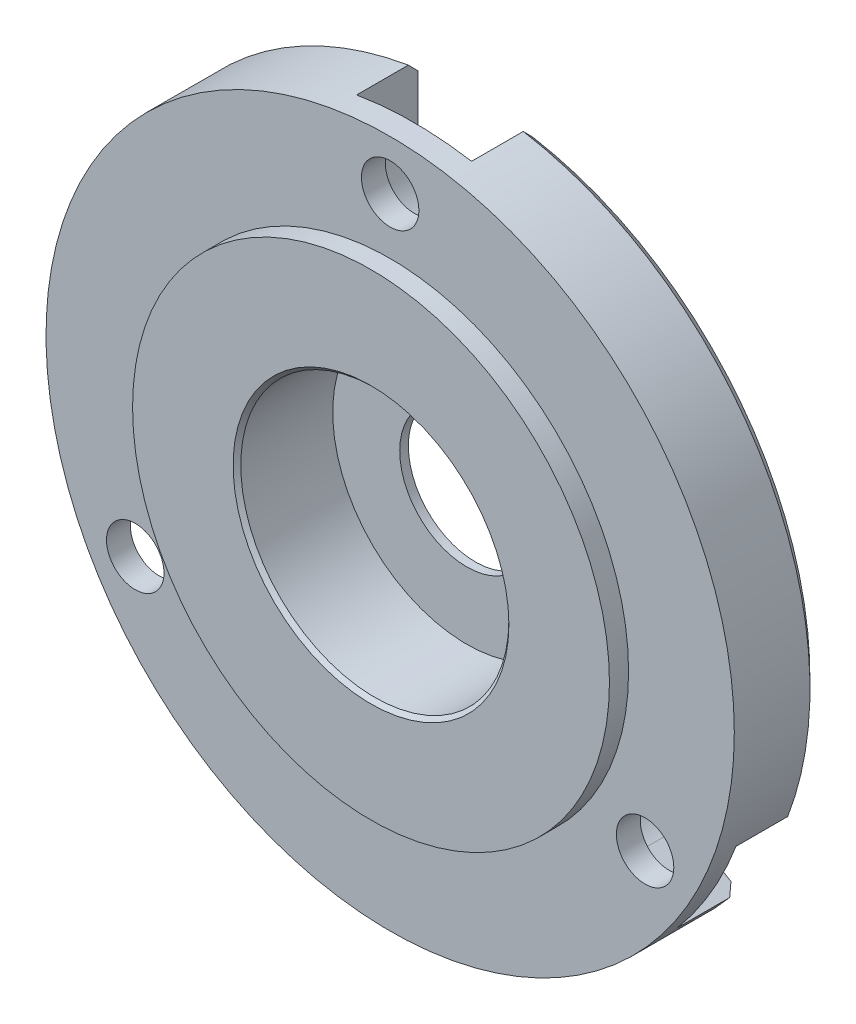
from build123d import *

# Parameters (mm, degrees)
ESQUISSE1_R             = 17.97
BOSS_EXTRU_1_DEPTH      = 4.45
ESQUISSE2_R             = 12.45
BOSS_EXTRU_2_DEPTH      = 1
CHANFREIN1_SIZE         = 0.5
ESQUISSE5_R             = 1.5
ENL_V_MAT_EXTRU_1_DEPTH = 6.45
ESQUISSE6_R             = 3.5
ENL_V_MAT_EXTRU_2_DEPTH = 6.45
ESQUISSE7_R             = 7
ENL_V_MAT_EXTRU_3_DEPTH = 5
ENL_V_MAT_EXTRU_4_DEPTH = 3.2
CHANFREIN2_SIZE         = 0.2


with BuildPart() as part:
    # Esquisse1 → Boss.-Extru.1 (new body)
    with BuildSketch(Plane.XY):
        with Locations((-74.842203198, 51.872077922)):
            Circle(ESQUISSE1_R)
    extrude(amount=BOSS_EXTRU_1_DEPTH)

    # Esquisse2 → Boss.-Extru.2 (add)
    with BuildSketch(Plane.XY.offset(4.45)):
        with Locations((-74.842203198, 51.872077922)):
            Circle(ESQUISSE2_R)
    extrude(amount=BOSS_EXTRU_2_DEPTH)

    # Chanfrein1
    chanfrein1_edges = [part.edges().sort_by_distance(p)[0] for p in [
        (-92.812203198, 51.872077922, 0),
    ]]
    chamfer(chanfrein1_edges, length=CHANFREIN1_SIZE)

    # Esquisse5 → Enlèv. mat.-Extru.1 (cut, through all)
    with BuildSketch(Plane(origin=(0, 0, 0), x_dir=(-1, 0, 0), z_dir=(0, 0, -1))):
        with Locations((74.842203198, 67.242077922)):
            Circle(ESQUISSE5_R)
        with Locations((61.531392742, 44.187077922)):
            Circle(ESQUISSE5_R)
        with Locations((88.153013654, 44.187077922)):
            Circle(ESQUISSE5_R)
    extrude(amount=-ENL_V_MAT_EXTRU_1_DEPTH, mode=Mode.SUBTRACT)

    # Esquisse6 → Enlèv. mat.-Extru.2 (cut, through all)
    with BuildSketch(Plane(origin=(0, 0, 0), x_dir=(-1, 0, 0), z_dir=(0, 0, -1))):
        with Locations((74.842203198, 51.872077922)):
            Circle(ESQUISSE6_R)
    extrude(amount=-ENL_V_MAT_EXTRU_2_DEPTH, mode=Mode.SUBTRACT)

    # Esquisse7 → Enlèv. mat.-Extru.3 (cut)
    with BuildSketch(Plane.XY.offset(5.45)):
        with Locations((-74.842203198, 51.872077922)):
            Circle(ESQUISSE7_R)
    extrude(amount=-ENL_V_MAT_EXTRU_3_DEPTH, mode=Mode.SUBTRACT)

    # Esquisse8 → Enlèv. mat.-Extru.4 (cut)
    with BuildSketch(Plane(origin=(0, 0, 0), x_dir=(-1, 0, 0), z_dir=(0, 0, -1))):
        with BuildLine():
            Line((71.842203198, 70.411905134), (71.842203198, 66.363654544))
            ThreePointArc((71.842203198, 66.363654544), (74.842203198, 63.363654544), (77.842203198, 66.363654544))
            Line((77.842203198, 66.363654544), (77.842203198, 70.411905134))
            Line((77.842203198, 70.411905134), (71.842203198, 70.411905134))
        make_face()
        with BuildLine():
            Line((60.379554388, 39.925212907), (63.849582418, 42.010216097))
            ThreePointArc((63.849582418, 42.010216097), (64.875970095, 46.126832224), (60.759353968, 47.153219901))
            Line((60.759353968, 47.153219901), (57.289325938, 45.068216711))
            Line((57.289325938, 45.068216711), (60.379554388, 39.925212907))
        make_face()
        with BuildLine():
            Line((92.371338943, 45.133431645), (88.865451092, 47.15755694))
            ThreePointArc((88.865451092, 47.15755694), (84.76737488, 46.059480728), (85.865451092, 41.961404517))
            Line((85.865451092, 41.961404517), (89.371338943, 39.937279222))
            Line((89.371338943, 39.937279222), (92.371338943, 45.133431645))
        make_face()
    extrude(amount=-ENL_V_MAT_EXTRU_4_DEPTH, mode=Mode.SUBTRACT)

    # Chanfrein2
    chanfrein2_edges = [part.edges().sort_by_distance(p)[0] for p in [
        (-81.842203198, 51.872077922, 5.45),
    ]]
    chamfer(chanfrein2_edges, length=CHANFREIN2_SIZE)


solid = part.part
